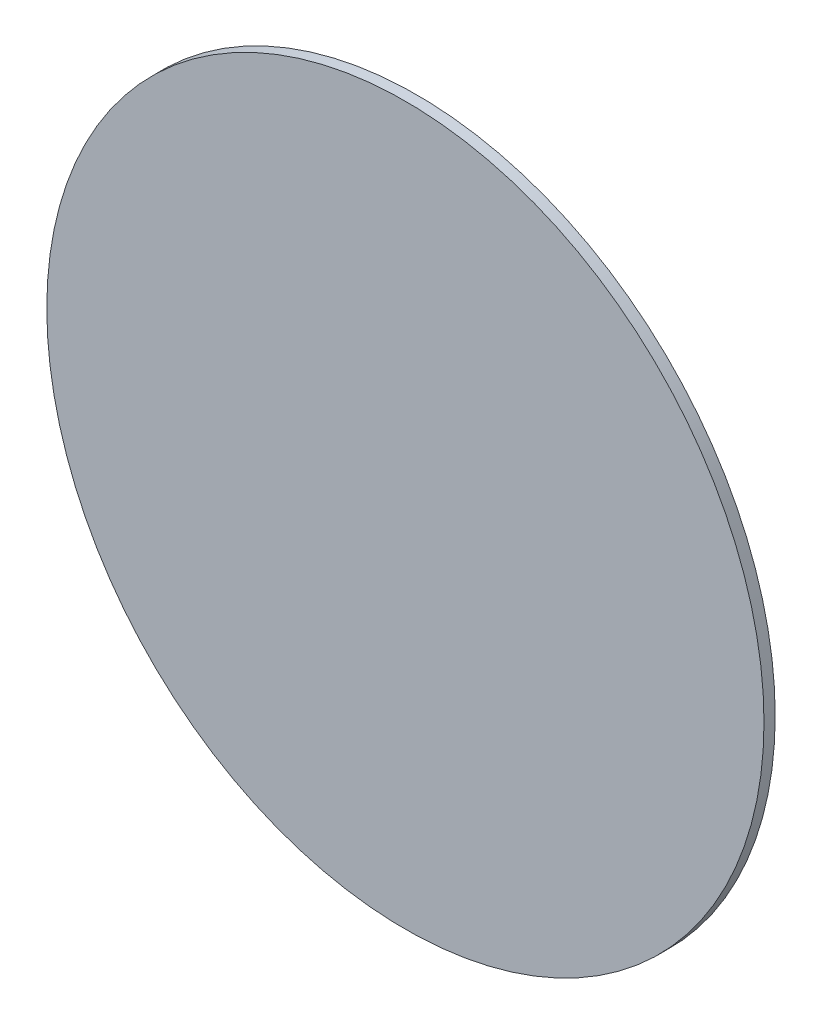
from build123d import *

# Parameters (mm, degrees)
SKETCH1_R           = 101.6
BOSS_EXTRUDE1_DEPTH = 3.175


with BuildPart() as part:
    # Sketch1 → Boss-Extrude1 (new body)
    with BuildSketch(Plane.XY):
        with Locations((0, -145.57583625)):
            Circle(SKETCH1_R)
    extrude(amount=BOSS_EXTRUDE1_DEPTH)


solid = part.part
